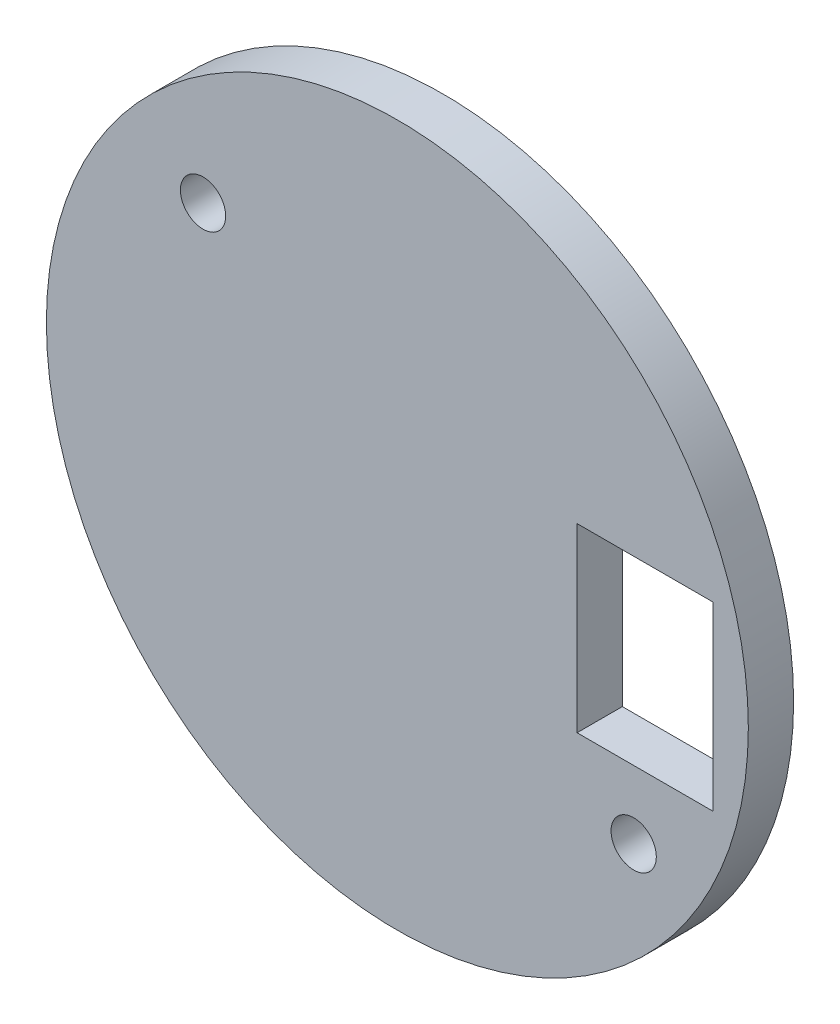
from build123d import *

# Parameters (mm, degrees)
SKETCH1_R           = 15.5
SKETCH1_R_2         = 1
SKETCH1_W           = 8
SKETCH1_H           = 6
BOSS_EXTRUDE1_DEPTH = 2


with BuildPart() as part:
    # Sketch1 → Boss-Extrude1 (new body)
    with BuildSketch(Plane(origin=(0, 0, 0), x_dir=(0, -1, 0), z_dir=(0, 0, 1))):
        Circle(SKETCH1_R)
        with Locations((6.97426488, 10.435972737)):
            Circle(SKETCH1_R_2, mode=Mode.SUBTRACT)
        with Locations((-8.02573512, -8.580948715)):
            Circle(SKETCH1_R_2, mode=Mode.SUBTRACT)
        with Locations((-0.025715642, 10.93618237)):
            Rectangle(SKETCH1_W, SKETCH1_H, mode=Mode.SUBTRACT)
    extrude(amount=BOSS_EXTRUDE1_DEPTH)


solid = part.part
